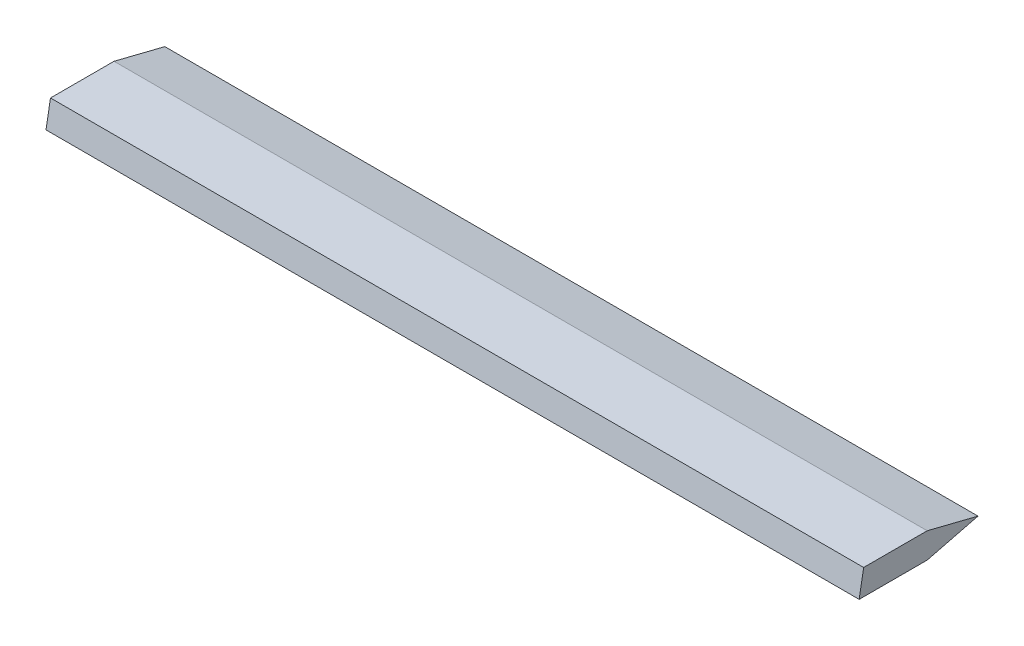
from build123d import *

# Parameters (mm, degrees)
BOSS_EXTRUDE1_DEPTH = 81.28


with BuildPart() as part:
    # Sketch1 → Boss-Extrude1 (new body)
    with BuildSketch(Plane(origin=(0, 0, 0), x_dir=(0, 0, -1), z_dir=(1, 0, 0))):
        Polygon((0, 0), (6.35, 0), (11.43, -1.27), (6.35, -2.54), (-0.447870531, -2.54), align=None)
    extrude(amount=BOSS_EXTRUDE1_DEPTH)


solid = part.part
